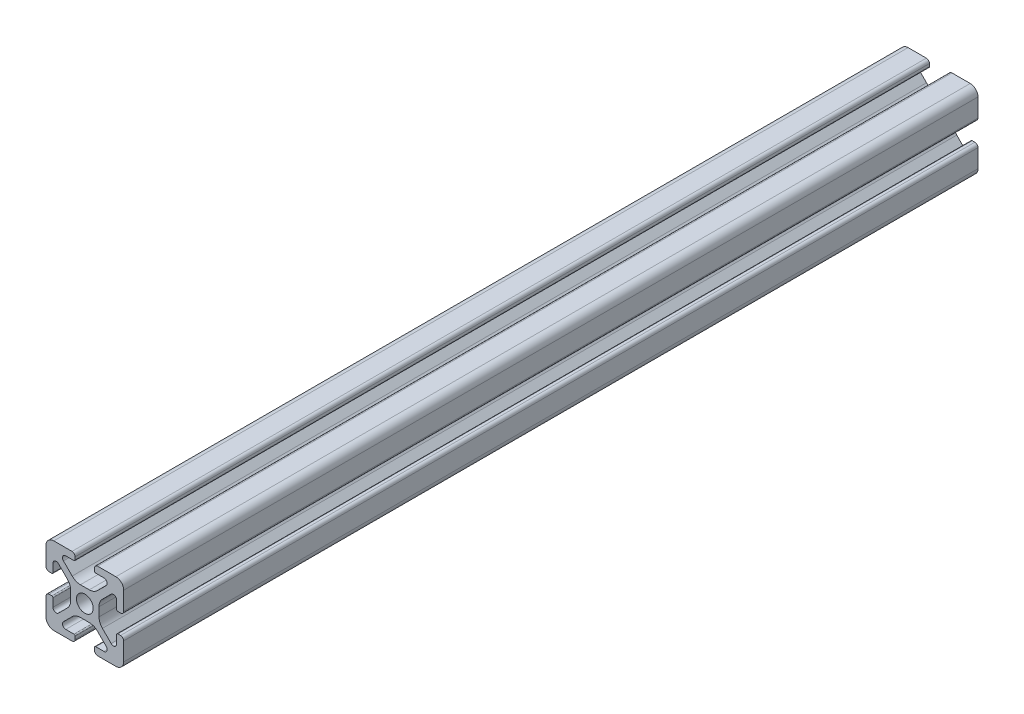
from build123d import *

# Parameters (mm, degrees)
SKETCH4_W              = 20
SKETCH4_H              = 20
BODY_DEPTH             = 220
SKETCH16_OUTSIDE_W     = 66.362
SKETCH16_OUTSIDE_H     = 66.362
SKETCH16_OUTSIDE_R     = 2.15
CUT_PROFILE_DEPTH      = 26
CUT_PROFILE_DEPTH_BACK = 196


with BuildPart() as part:
    # Sketch4 → Body (new body)
    with BuildSketch(Plane.XY.offset(25)):
        Rectangle(SKETCH4_W, SKETCH4_H)
    extrude(amount=-BODY_DEPTH)

    # Sketch16 outside → Cut-Profile (cut, two sides)
    with BuildSketch(Plane.XY) as cut_profile_sk:
        Rectangle(SKETCH16_OUTSIDE_W, SKETCH16_OUTSIDE_H)
        with BuildLine():
            Line((4.917588389, -8.199999991), (2.799999989, -8.199999991))
            ThreePointArc((2.799999989, -8.199999991), (2.587867955, -8.287867957), (2.499999989, -8.499999991))
            Line((2.499999989, -8.499999991), (2.499999989, -9.199999991))
            ThreePointArc((2.499999989, -9.199999991), (2.734314564, -9.765685416), (3.299999989, -9.999999991))
            Line((3.299999989, -9.999999991), (7.999999989, -9.999999991))
            ThreePointArc((7.999999989, -9.999999991), (9.414213552, -9.414213554), (9.999999989, -7.999999991))
            Line((9.999999989, -7.999999991), (9.999999989, -3.299999991))
            ThreePointArc((9.999999989, -3.299999991), (9.765685414, -2.734314566), (9.199999989, -2.499999991))
            Line((9.199999989, -2.499999991), (8.499999989, -2.499999991))
            ThreePointArc((8.499999989, -2.499999991), (8.287867955, -2.587867957), (8.199999989, -2.799999991))
            Line((8.199999989, -2.799999991), (8.199999989, -4.917588391))
            ThreePointArc((8.199999989, -4.917588391), (7.686138511, -5.686636441), (6.778984485, -5.506192286))
            Line((6.778984485, -5.506192286), (4.528679645, -3.255887446))
            ThreePointArc((4.528679645, -3.255887446), (3.878361392, -2.282617401), (3.64999999, -1.134567106))
            Line((3.64999999, -1.134567106), (3.64999999, 1.134567104))
            ThreePointArc((3.64999999, 1.134567104), (3.878361393, 2.282617402), (4.528679647, 3.255887448))
            Line((4.528679647, 3.255887448), (6.778984487, 5.506192288))
            ThreePointArc((6.778984487, 5.506192288), (7.686138506, 5.686636442), (8.199999981, 4.917588398))
            Line((8.199999981, 4.917588398), (8.199999981, 2.799999998))
            ThreePointArc((8.199999981, 2.799999998), (8.287867946, 2.587867964), (8.499999981, 2.499999998))
            Line((8.499999981, 2.499999998), (9.199999981, 2.499999998))
            ThreePointArc((9.199999981, 2.499999998), (9.765685406, 2.734314573), (9.999999981, 3.299999998))
            Line((9.999999981, 3.299999998), (9.999999981, 7.999999998))
            ThreePointArc((9.999999981, 7.999999998), (9.414213543, 9.41421356), (7.999999981, 9.999999998))
            Line((7.999999981, 9.999999998), (3.299999981, 9.999999998))
            ThreePointArc((3.299999981, 9.999999998), (2.734314556, 9.765685423), (2.499999981, 9.199999998))
            Line((2.499999981, 9.199999998), (2.499999981, 8.499999998))
            ThreePointArc((2.499999981, 8.499999998), (2.587867946, 8.287867964), (2.799999981, 8.199999998))
            Line((2.799999981, 8.199999998), (4.917588381, 8.199999998))
            ThreePointArc((4.917588381, 8.199999998), (5.68663643, 7.68613852), (5.506192275, 6.778984494))
            Line((5.506192275, 6.778984494), (3.255887435, 4.528679654))
            ThreePointArc((3.255887435, 4.528679654), (2.28261739, 3.878361401), (1.134567095, 3.649999999))
            Line((1.134567095, 3.649999999), (-1.134567115, 3.649999999))
            ThreePointArc((-1.134567115, 3.649999999), (-2.282617412, 3.878361401), (-3.255887459, 4.528679655))
            Line((-3.255887459, 4.528679655), (-5.506192299, 6.778984495))
            ThreePointArc((-5.506192299, 6.778984495), (-5.686636452, 7.686138515), (-4.917588409, 8.199999989))
            Line((-4.917588409, 8.199999989), (-2.800000009, 8.199999989))
            ThreePointArc((-2.800000009, 8.199999989), (-2.587867974, 8.287867955), (-2.500000009, 8.499999989))
            Line((-2.500000009, 8.499999989), (-2.500000009, 9.199999989))
            ThreePointArc((-2.500000009, 9.199999989), (-2.734314584, 9.765685414), (-3.300000009, 9.999999989))
            Line((-3.300000009, 9.999999989), (-8.000000009, 9.999999989))
            ThreePointArc((-8.000000009, 9.999999989), (-9.414213571, 9.414213552), (-10.000000009, 7.999999989))
            Line((-10.000000009, 7.999999989), (-10.000000009, 3.299999989))
            ThreePointArc((-10.000000009, 3.299999989), (-9.765685434, 2.734314564), (-9.200000009, 2.499999989))
            Line((-9.200000009, 2.499999989), (-8.500000009, 2.499999989))
            ThreePointArc((-8.500000009, 2.499999989), (-8.287867974, 2.587867955), (-8.200000009, 2.799999989))
            Line((-8.200000009, 2.799999989), (-8.200000009, 4.917588389))
            ThreePointArc((-8.200000009, 4.917588389), (-7.686138531, 5.686636438), (-6.778984504, 5.506192284))
            Line((-6.778984504, 5.506192284), (-4.528679664, 3.255887444))
            ThreePointArc((-4.528679664, 3.255887444), (-3.878361412, 2.282617399), (-3.650000009, 1.134567104))
            Line((-3.650000009, 1.134567104), (-3.650000009, -1.134567106))
            ThreePointArc((-3.650000009, -1.134567106), (-3.878361412, -2.282617404), (-4.528679666, -3.25588745))
            Line((-4.528679666, -3.25588745), (-6.778984506, -5.50619229))
            ThreePointArc((-6.778984506, -5.50619229), (-7.686138526, -5.686636444), (-8.2, -4.9175884))
            Line((-8.2, -4.9175884), (-8.2, -2.8))
            ThreePointArc((-8.2, -2.8), (-8.287867966, -2.587867966), (-8.5, -2.5))
            Line((-8.5, -2.5), (-9.2, -2.5))
            ThreePointArc((-9.2, -2.5), (-9.765685425, -2.734314575), (-10, -3.3))
            Line((-10, -3.3), (-10, -8))
            ThreePointArc((-10, -8), (-9.414213562, -9.414213562), (-8, -10))
            Line((-8, -10), (-3.3, -10))
            ThreePointArc((-3.3, -10), (-2.734314575, -9.765685425), (-2.5, -9.2))
            Line((-2.5, -9.2), (-2.5, -8.5))
            ThreePointArc((-2.5, -8.5), (-2.587867966, -8.287867966), (-2.8, -8.2))
            Line((-2.8, -8.2), (-4.9175884, -8.2))
            ThreePointArc((-4.9175884, -8.2), (-5.686636449, -7.686138522), (-5.506192294, -6.778984496))
            Line((-5.506192294, -6.778984496), (-3.255887454, -4.528679656))
            ThreePointArc((-3.255887454, -4.528679656), (-2.282617409, -3.878361403), (-1.134567114, -3.650000001))
            Line((-1.134567114, -3.650000001), (1.134567096, -3.650000001))
            ThreePointArc((1.134567096, -3.650000001), (2.282617393, -3.878361403), (3.255887439, -4.528679657))
            Line((3.255887439, -4.528679657), (5.506192279, -6.778984497))
            ThreePointArc((5.506192279, -6.778984497), (5.686636433, -7.686138517), (4.917588389, -8.199999991))
        make_face(mode=Mode.SUBTRACT)
        Circle(SKETCH16_OUTSIDE_R)
    extrude(amount=CUT_PROFILE_DEPTH, mode=Mode.SUBTRACT)
    extrude(cut_profile_sk.sketch, amount=-CUT_PROFILE_DEPTH_BACK, mode=Mode.SUBTRACT)


solid = part.part
